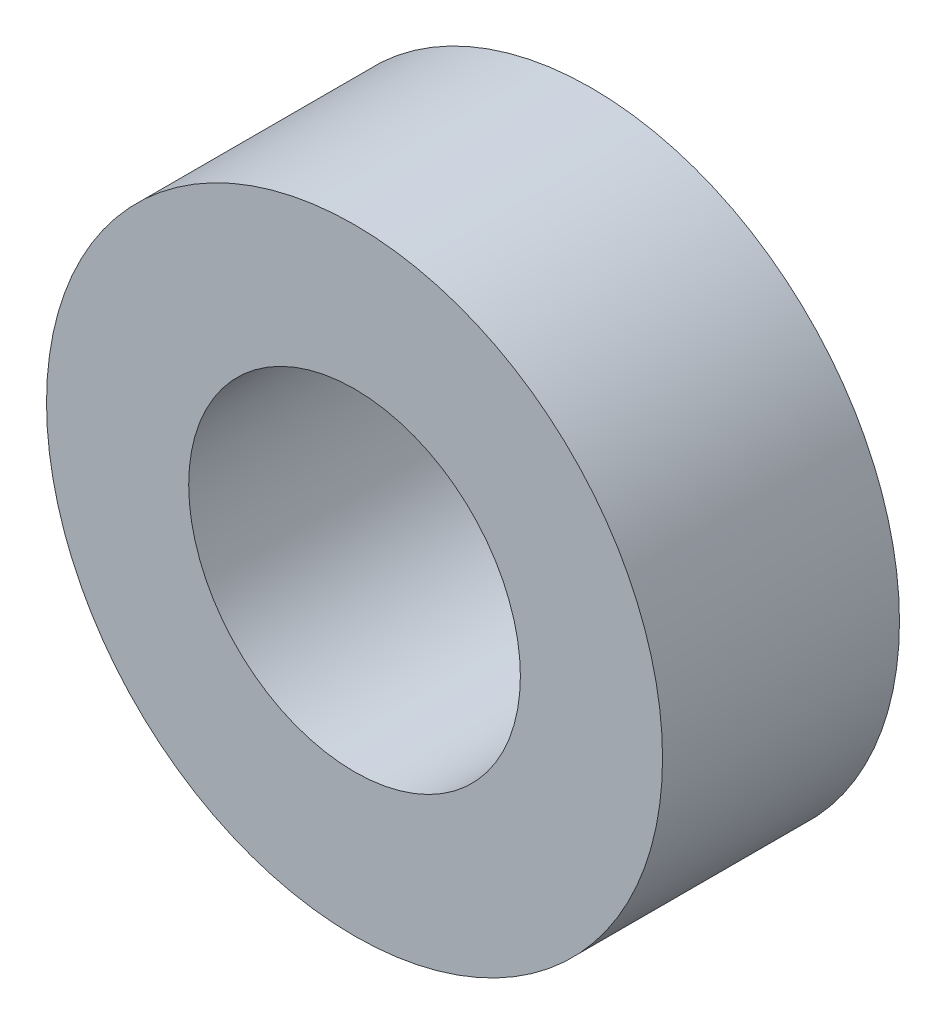
from build123d import *

# Parameters (mm, degrees)
SKETCH_1_R      = 6.5
SKETCH_1_R_2    = 3.5
EXTRUDE_1_DEPTH = 5


with BuildPart() as part:
    # Эскиз1 → Бобышка-Вытянуть1 (new body)
    with BuildSketch(Plane.XY):
        Circle(SKETCH_1_R)
        Circle(SKETCH_1_R_2, mode=Mode.SUBTRACT)
    extrude(amount=EXTRUDE_1_DEPTH)


solid = part.part
